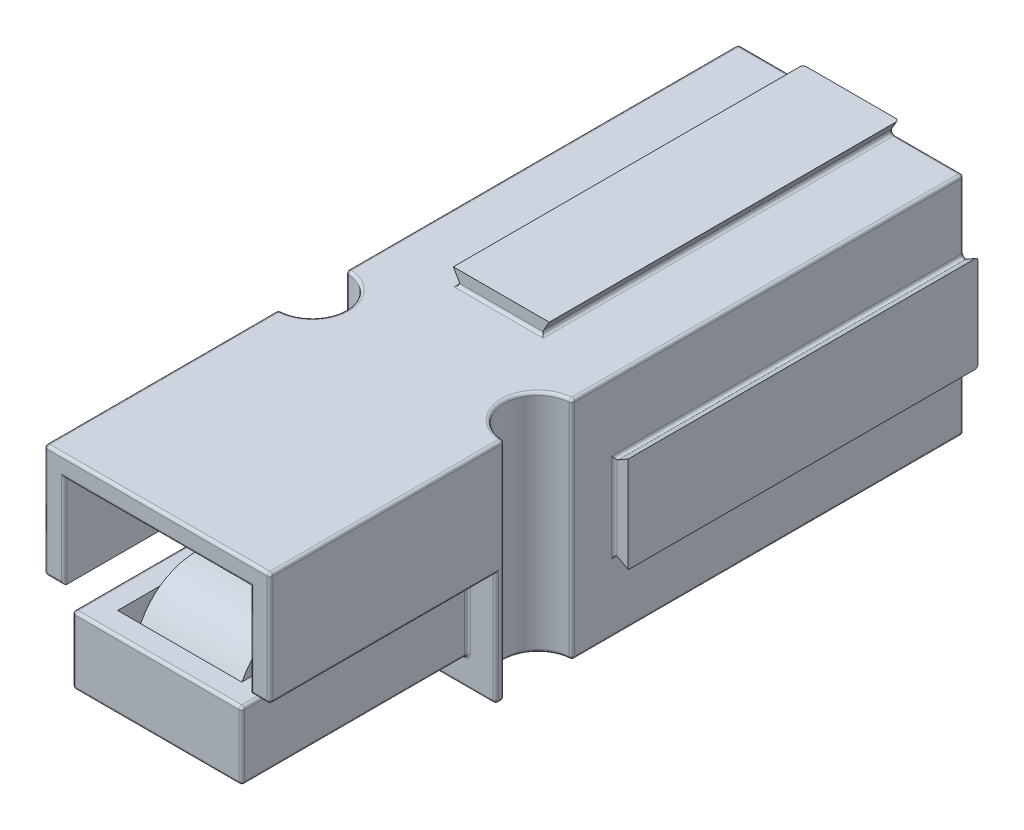
from build123d import *

# Parameters (mm, degrees)
ESQUISSE1_W              = 8.5
ESQUISSE1_H              = 8.5
EXTRUSION1_DEPTH         = 24.6
ESQUISSE6_W              = 3.050497429
ESQUISSE6_H              = 0.5
ESQUISSE6_W_2            = 2.3
ENL_V_MAT_EXTRU_4_DEPTH  = 25.6
ESQUISSE2_W              = 0.5
ESQUISSE2_H              = 2.8
ESQUISSE2_H_2            = 2.3
ENL_V_MAT_EXTRU_1_DEPTH  = 25.6
ESQUISSE4_R              = 1.2
ENL_V_MAT_EXTRU_3_DEPTH  = 9
ESQUISSE11_W             = 3.4
ESQUISSE11_H             = 0.5
ESQUISSE11_W_2           = 0.5
ESQUISSE11_H_2           = 3.4
ENL_V_MAT_EXTRU_9_DEPTH  = 12.2
ENL_V_MAT_EXTRU_5_DEPTH  = 8
ESQUISSE7_W              = 6.6
ESQUISSE7_H              = 3.9
ENL_V_MAT_EXTRU_6_DEPTH  = 8
ESQUISSE8_W              = 5.2
ESQUISSE8_H              = 5.2
ENL_V_MAT_EXTRU_7_DEPTH  = 8
ENL_V_MAT_EXTRU_8_DEPTH  = 13
ENL_V_MAT_EXTRU_10_DEPTH = 12.4
ESQUISSE14_W             = 4.4
ESQUISSE14_H             = 6.4
ENL_V_MAT_EXTRU_11_DEPTH = 1.75
ESQUISSE15_W             = 4.4
ESQUISSE15_H             = 1.75
ENL_V_MAT_EXTRU_12_DEPTH = 0.8
FILLET1_R                = 0.1
SKETCH1_R                = 2
CUT_EXTRUDE1_DEPTH       = 7.6
SCALE1_SCALE             = 1.95
EXTRUSION2_DEPTH         = 3.5


with BuildPart() as part:
    # Esquisse1 → Extrusion1 (new body)
    with BuildSketch(Plane.XY):
        Rectangle(ESQUISSE1_W, ESQUISSE1_H)
    extrude(amount=EXTRUSION1_DEPTH)

    # Esquisse6 → Enlèv. mat.-Extru.4 (cut, through all)
    with BuildSketch(Plane.XY.offset(24.6)):
        with Locations((2.975248715, 4)):
            Rectangle(ESQUISSE6_W, ESQUISSE6_H)
        with Locations((-3.1, 4)):
            Rectangle(ESQUISSE6_W_2, ESQUISSE6_H)
    extrude(amount=-ENL_V_MAT_EXTRU_4_DEPTH, mode=Mode.SUBTRACT)

    # Esquisse2 → Enlèv. mat.-Extru.1 (cut, through all)
    with BuildSketch(Plane.XY.offset(24.6)):
        with Locations((4, 2.85)):
            Rectangle(ESQUISSE2_W, ESQUISSE2_H)
        with Locations((4, -3.1)):
            Rectangle(ESQUISSE2_W, ESQUISSE2_H_2)
    extrude(amount=-ENL_V_MAT_EXTRU_1_DEPTH, mode=Mode.SUBTRACT)

    # Esquisse4 → Enlèv. mat.-Extru.3 (cut, through all)
    with BuildSketch(Plane(origin=(0, 3.75, 0), x_dir=(-1, 0, 0), z_dir=(0, 1, 0))):
        with Locations((-3.75, 15.1)):
            Circle(ESQUISSE4_R)
        with Locations((4.25, 15.1)):
            Circle(ESQUISSE4_R)
    extrude(amount=-ENL_V_MAT_EXTRU_3_DEPTH, mode=Mode.SUBTRACT)

    # Esquisse11 → Enlèv. mat.-Extru.9 (cut)
    with BuildSketch(Plane.XY.offset(24.6)):
        with Locations((-0.25, 4)):
            Rectangle(ESQUISSE11_W, ESQUISSE11_H)
        with Locations((4, -0.25)):
            Rectangle(ESQUISSE11_W_2, ESQUISSE11_H_2)
    extrude(amount=-ENL_V_MAT_EXTRU_9_DEPTH, mode=Mode.SUBTRACT)

    # Esquisse5 → Enlèv. mat.-Extru.5 (cut)
    with BuildSketch(Plane.XY.offset(24.6)):
        Polygon((-4.25, -0.25), (-3.25, -0.25), (-3.25, -3.25), (2.75, -3.25), (2.75, -0.25), (3.75, -0.25), (3.75, -4.25), (-4.25, -4.25), align=None)
    extrude(amount=-ENL_V_MAT_EXTRU_5_DEPTH, mode=Mode.SUBTRACT)

    # Esquisse7 → Enlèv. mat.-Extru.6 (cut)
    with BuildSketch(Plane.XY.offset(24.6)):
        with Locations((-0.25, 1.1)):
            Rectangle(ESQUISSE7_W, ESQUISSE7_H)
    extrude(amount=-ENL_V_MAT_EXTRU_6_DEPTH, mode=Mode.SUBTRACT)

    # Esquisse8 → Enlèv. mat.-Extru.7 (cut)
    with BuildSketch(Plane(origin=(0, 0, 0), x_dir=(-1, 0, 0), z_dir=(0, 0, -1))):
        with Locations((0.25, -0.25)):
            Rectangle(ESQUISSE8_W, ESQUISSE8_H)
    extrude(amount=-ENL_V_MAT_EXTRU_7_DEPTH, mode=Mode.SUBTRACT)

    # Esquisse9 → Enlèv. mat.-Extru.8 (cut)
    with BuildSketch(Plane(origin=(0, 0, 0), x_dir=(-1, 0, 0), z_dir=(0, 0, -1))):
        Polygon((-1.45, 4.25), (-1.161324865, 3.75), (-1.45, 3.75), align=None)
        Polygon((1.95, 3.75), (1.95, 4.25), (1.661324865, 3.75), align=None)
        Polygon((-4.25, 1.45), (-3.75, 1.161324865), (-3.75, 1.45), align=None)
        Polygon((-3.75, -1.95), (-4.25, -1.95), (-3.75, -1.661324865), align=None)
    extrude(amount=-ENL_V_MAT_EXTRU_8_DEPTH, mode=Mode.SUBTRACT)

    # Esquisse12 → Enlèv. mat.-Extru.10 (cut)
    with BuildSketch(Plane(origin=(0, 0, 0), x_dir=(-1, 0, 0), z_dir=(0, 0, -1))):
        Polygon((4.25, 1.161324865), (4.25, -1.661324865), (3.75, -1.95), (3.75, 1.45), align=None)
        Polygon((-1.161324865, -4.25), (1.661324865, -4.25), (1.95, -3.75), (-1.45, -3.75), align=None)
    extrude(amount=-ENL_V_MAT_EXTRU_10_DEPTH, mode=Mode.SUBTRACT)

    # Esquisse14 → Enlèv. mat.-Extru.11 (cut)
    with BuildSketch(Plane(origin=(0, -0.85, 0), x_dir=(-1, 0, 0), z_dir=(0, 1, 0))):
        with Locations((0.25, 20.6)):
            Rectangle(ESQUISSE14_W, ESQUISSE14_H)
    extrude(amount=-ENL_V_MAT_EXTRU_11_DEPTH, mode=Mode.SUBTRACT)

    # Esquisse15 → Enlèv. mat.-Extru.12 (cut)
    with BuildSketch(Plane.XY.offset(17.4)):
        with Locations((-0.25, -1.725)):
            Rectangle(ESQUISSE15_W, ESQUISSE15_H)
    extrude(amount=-ENL_V_MAT_EXTRU_12_DEPTH, mode=Mode.SUBTRACT)

    # Fillet1
    fillet1_edges = [part.edges().sort_by_distance(p)[0] for p in [
        (-4.25, 2.455662433, 0),
        (-4.25, 1.75, 24.6),
        (-4.25, -4.25, 16.45),
        (-4.25, -2.25, 16.6),
        (-4.25, -0.25, 20.6),
        (-3.25, -2.05, 16.6),
        (-0.25, -3.25, 16.6),
        (-3.25, -3.25, 20.6),
        (2.75, -3.25, 20.6),
        (3.75, -2.25, 16.6),
        (3.75, -0.25, 20.6),
        (-0.25, -4.25, 16.6),
        (3.4, -0.25, 24.6),
        (-0.25, -3.25, 24.6),
        (-3.25, -2.05, 24.6),
        (2.75, -2.05, 16.6),
        (-4.25, 3.75, 6.95),
        (2.75, -2.05, 24.6),
        (-3.9, -0.25, 24.6),
        (-0.25, -0.85, 24.6),
        (3.05, 1.4, 24.6),
        (-0.25, 3.05, 24.6),
        (-3.55, 1.4, 24.6),
        (2.35, -0.85, 16.6),
        (-3.25, -0.85, 20.6),
        (2.75, -0.85, 20.6),
        (-2.955662433, 3.75, 0),
        (-0.25, 3.75, 24.6),
        (-0.25, 2.35, 0),
        (2.35, -0.25, 0),
        (-0.25, -2.85, 0),
        (-2.85, -0.25, 0),
        (1.161324865, 3.75, 6.2),
        (1.305662433, 4, 0),
        (-0.25, 3.75, 12.4),
        (-1.661324865, 3.75, 6.2),
        (-1.805662433, 4, 0),
        (3.75, -0.25, 12.4),
        (3.75, 1.161324865, 6.2),
        (4, 1.305662433, 0),
        (3.75, -1.661324865, 6.2),
        (4, -1.805662433, 0),
        (-4.25, -2.955662433, 0),
        (-4.25, -1.661324865, 6.2),
        (-4.25, -0.25, 12.4),
        (-4.25, 1.161324865, 6.2),
        (2.455662433, -4.25, 0),
        (1.161324865, -4.25, 6.2),
        (-0.25, -4.25, 12.4),
        (-1.661324865, -4.25, 6.2),
        (2.455662433, 3.75, 0),
        (-2.85, -0.85, 16.6),
        (3.75, 3.75, 20.45),
        (-2.955662433, -4.25, 0),
        (3.75, 2.455662433, 0),
        (3.75, 1.75, 24.6),
        (3.75, -2.955662433, 0),
        (3.75, -4.25, 6.95),
        (3.75, -4.25, 16.45),
        (3.75, 3.75, 6.95),
        (2.55, 3.75, 15.1),
        (3.75, -0.25, 16.3),
        (3.75, -0.25, 13.9),
        (2.55, -4.25, 15.1),
        (-4.25, 3.75, 20.45),
        (-3.05, 3.75, 15.1),
        (-4.25, -4.25, 6.95),
        (-3.05, -4.25, 15.1),
        (-4.25, -0.25, 13.9),
        (-4.25, -0.25, 16.3),
    ]]
    fillet(fillet1_edges, radius=FILLET1_R)

    # Sketch1 → Cut-Extrude1 (cut)
    with BuildSketch(Plane(origin=(0, 0, 8), x_dir=(-1, 0, 0), z_dir=(0, 0, -1))):
        with Locations((0.25, -0.25)):
            Circle(SKETCH1_R)
    extrude(amount=-CUT_EXTRUDE1_DEPTH, mode=Mode.SUBTRACT)


with BuildPart() as part_1:
    # Scale1: scaled about (-0.067943919, 0.04760782, 10.766314315)
    add(part.part.scale(SCALE1_SCALE).moved(Location((0.064546723, -0.045227429, -10.227998599))))

    # Esquisse13 → Extrusion2 (add, symmetric)
    with BuildSketch(Plane(origin=(-0.25, 0, 0), x_dir=(0, 0, -1), z_dir=(1, 0, 0))):
        with BuildLine():
            Line((-30.120338288, -0.225174581), (-22.141999884, -3.397050581))
            Line((-22.141999884, -3.397050581), (-22.141999884, -4.042728289))
            Line((-22.141999884, -4.042728289), (-30.341999884, -0.782728289))
            ThreePointArc((-30.341999884, -0.782728289), (-33.227635167, -0.852998547), (-35.175988349, -2.982728289))
            Line((-35.175988349, -2.982728289), (-35.741999884, -2.783653072))
            ThreePointArc((-35.741999884, -2.783653072), (-33.476172744, -0.30689501), (-30.120338288, -0.225174581))
        make_face()
    extrude(amount=EXTRUSION2_DEPTH, both=True)


solid = part_1.part
